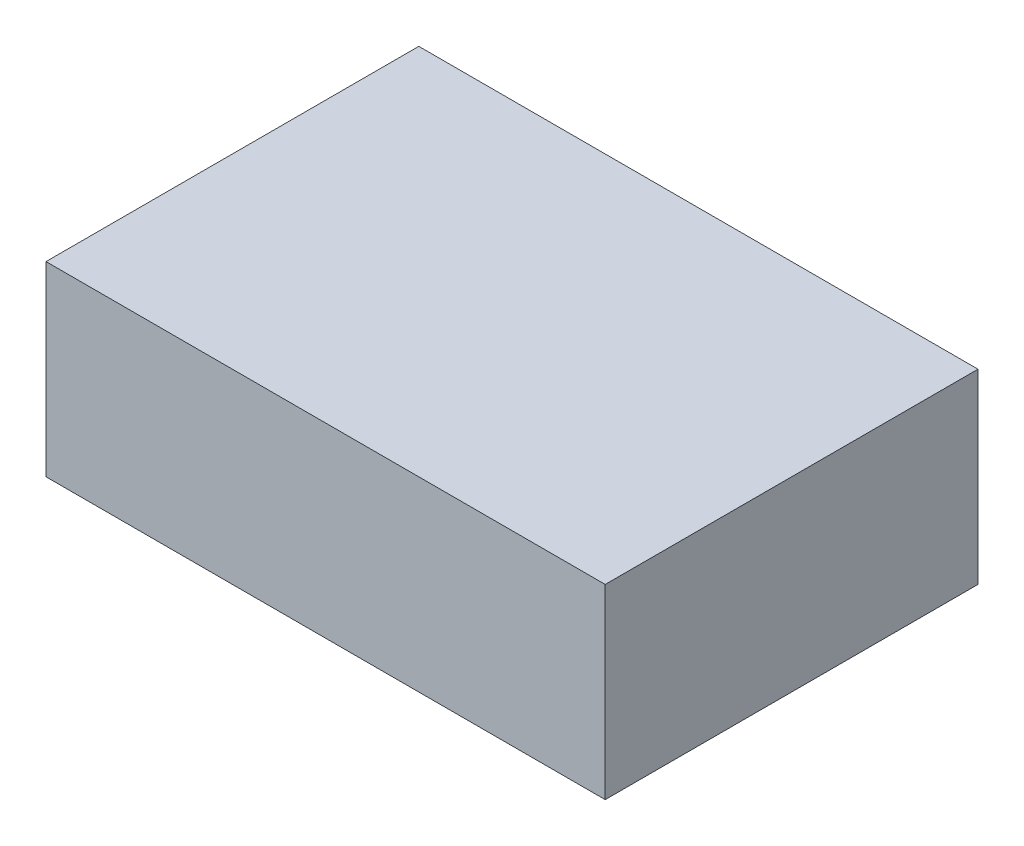
from build123d import *

# Parameters (mm, degrees)
SKETCH1_W           = 0.75
SKETCH1_H           = 0.5
BOSS_EXTRUDE1_DEPTH = 0.25


with BuildPart() as part:
    # Sketch1 → Boss-Extrude1 (new body)
    with BuildSketch(Plane(origin=(0, 0, 0), x_dir=(1, 0, 0), z_dir=(0, 1, 0))):
        with Locations((0.375, 0.25)):
            Rectangle(SKETCH1_W, SKETCH1_H)
    extrude(amount=BOSS_EXTRUDE1_DEPTH)


solid = part.part
